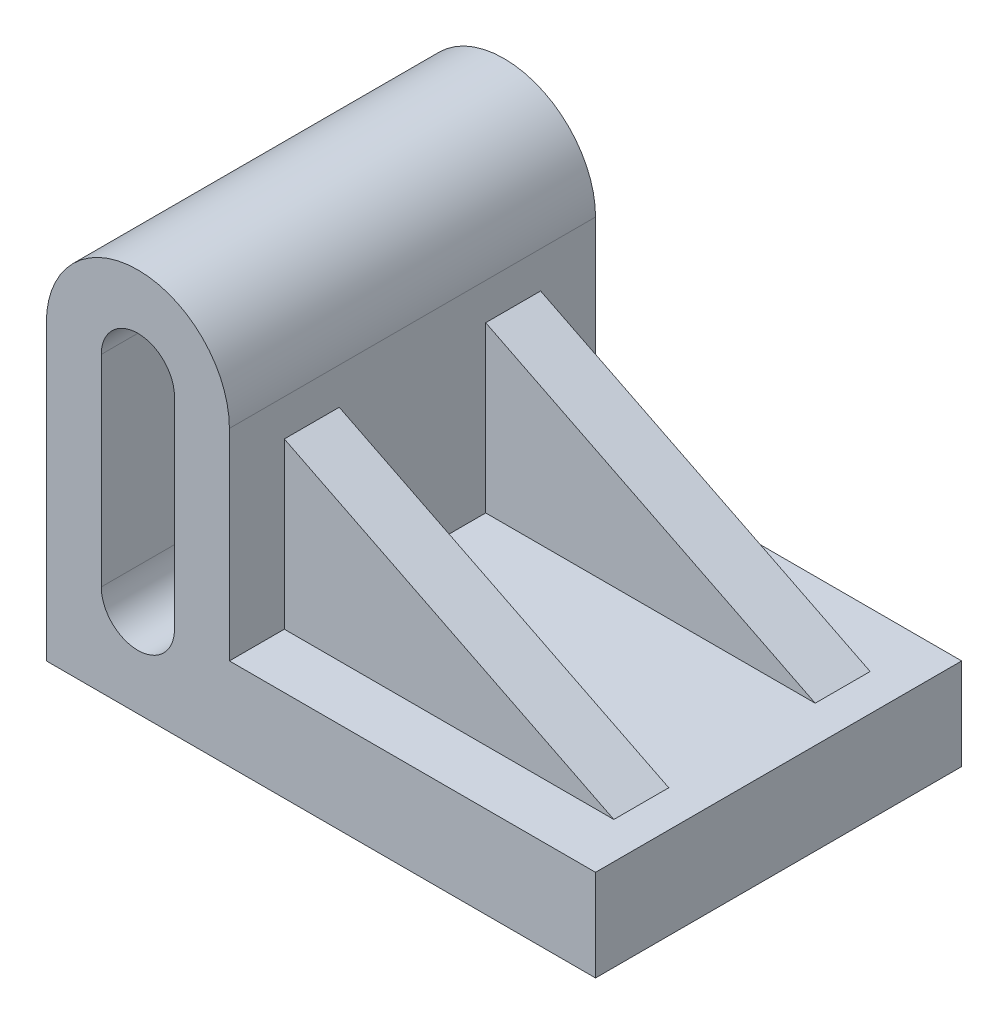
from build123d import *

# Parameters (mm, degrees)
BOSS_EXTRUDE1_DEPTH = 100
SKETCH4_W           = 90
SKETCH4_H           = 70
BOSS_EXTRUDE2_DEPTH = 45
SKETCH5_W           = 40
SKETCH5_H           = 45
CUT_EXTRUDE1_DEPTH  = 90
CUT_EXTRUDE2_DEPTH  = 70


with BuildPart() as part:
    # Sketch1 → Boss-Extrude1 (new body)
    with BuildSketch(Plane.XY):
        with BuildLine():
            Line((-52.117117117, 57.815315315), (-52.117117117, 2.815315315))
            Line((-52.117117117, 2.815315315), (47.882882883, 2.815315315))
            Line((47.882882883, 2.815315315), (47.882882883, -22.184684685))
            Line((47.882882883, -22.184684685), (-102.117117117, -22.184684685))
            Line((-102.117117117, -22.184684685), (-102.117117117, 2.815315315))
            Line((-102.117117117, 2.815315315), (-102.117117117, 57.815315315))
            ThreePointArc((-102.117117117, 57.815315315), (-77.117117117, 82.815315315), (-52.117117117, 57.815315315))
        make_face()
        with BuildLine():
            Line((-67.117117117, 57.815315315), (-67.117117117, 2.815315315))
            ThreePointArc((-67.117117117, 2.815315315), (-77.117117117, -7.184684685), (-87.117117117, 2.815315315))
            Line((-87.117117117, 2.815315315), (-87.117117117, 57.815315315))
            ThreePointArc((-87.117117117, 57.815315315), (-77.117117117, 67.815315315), (-67.117117117, 57.815315315))
        make_face(mode=Mode.SUBTRACT)
    extrude(amount=-BOSS_EXTRUDE1_DEPTH)

    # Sketch4 → Boss-Extrude2 (add)
    with BuildSketch(Plane(origin=(0, 2.815315315, 0), x_dir=(1, 0, 0), z_dir=(0, 1, 0))):
        with Locations((-7.117117117, 50)):
            Rectangle(SKETCH4_W, SKETCH4_H)
    extrude(amount=BOSS_EXTRUDE2_DEPTH)

    # Sketch5 → Cut-Extrude1 (cut)
    with BuildSketch(Plane(origin=(37.882882883, 0, 0), x_dir=(0, 0, -1), z_dir=(1, 0, 0))):
        with Locations((50, 25.315315315)):
            Rectangle(SKETCH5_W, SKETCH5_H)
    extrude(amount=-CUT_EXTRUDE1_DEPTH, mode=Mode.SUBTRACT)

    # Sketch6 → Cut-Extrude2 (cut)
    with BuildSketch(Plane.XY.offset(-15)):
        Polygon((-52.117117117, 47.815315315), (37.882882883, 2.815315315), (37.882882883, 47.815315315), align=None)
    extrude(amount=-CUT_EXTRUDE2_DEPTH, mode=Mode.SUBTRACT)


solid = part.part
